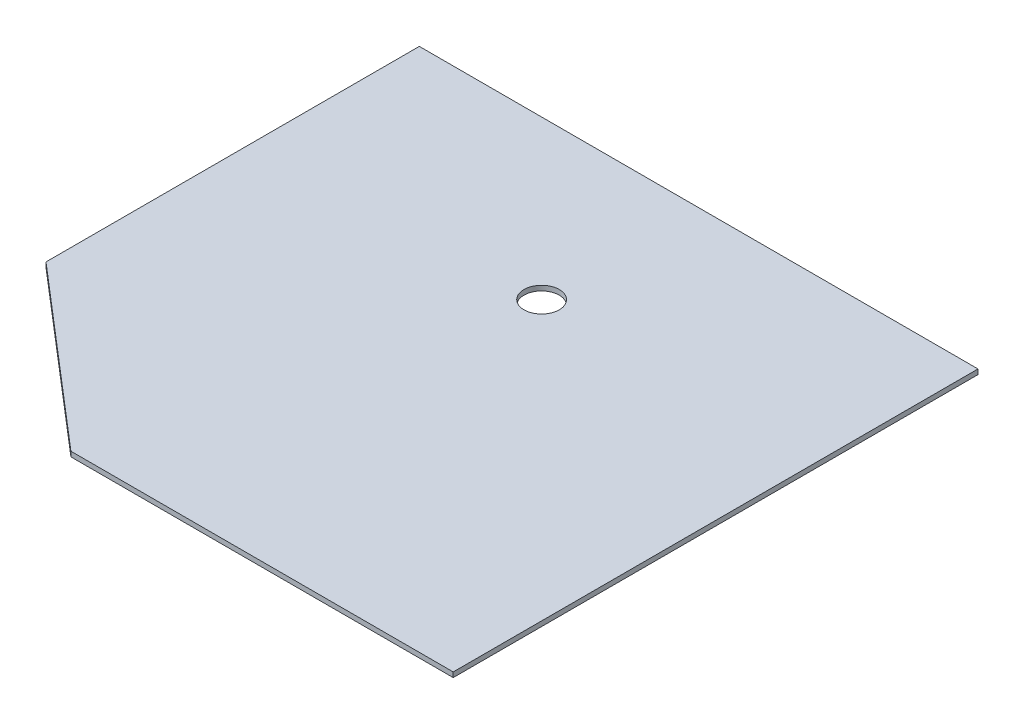
from build123d import *

# Parameters (mm, degrees)
SKETCH1_W           = 452.46
SKETCH1_H           = 425
BOSS_EXTRUDE1_DEPTH = 4
SKETCH2_R           = 14.275
CUT_EXTRUDE1_DEPTH  = 5
CUT_EXTRUDE2_DEPTH  = 5


with BuildPart() as part:
    # Sketch1 → Boss-Extrude1 (new body)
    with BuildSketch(Plane(origin=(0, 0, 0), x_dir=(1, 0, 0), z_dir=(0, 1, 0))):
        with Locations((12.58495796, 30.41049436)):
            Rectangle(SKETCH1_W, SKETCH1_H)
    extrude(amount=BOSS_EXTRUDE1_DEPTH)

    # Sketch2 → Cut-Extrude1 (cut, through all)
    with BuildSketch(Plane.XZ.offset(-4)):
        with Locations((13.51495796, -114.81049436)):
            Circle(SKETCH2_R)
    extrude(amount=CUT_EXTRUDE1_DEPTH, mode=Mode.SUBTRACT)

    # Sketch3 → Cut-Extrude2 (cut, through all)
    with BuildSketch(Plane(origin=(0, 4, 0), x_dir=(1, 0, 0), z_dir=(0, 1, 0))):
        Polygon((-70.791344552, -182.08950564), (-213.64504204, -59.421992734), (-317.358115476, -168.108607174), (-142.218193296, -320.092437945), align=None)
    extrude(amount=-CUT_EXTRUDE2_DEPTH, mode=Mode.SUBTRACT)


solid = part.part
